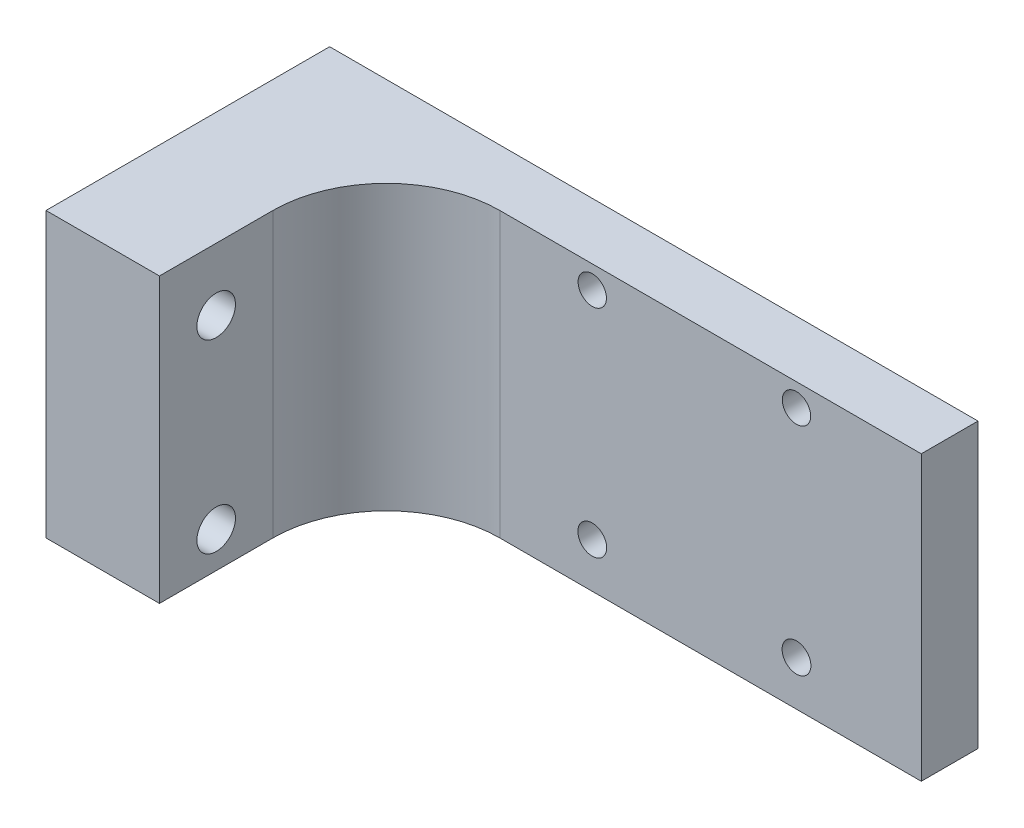
from build123d import *

# Parameters (mm, degrees)
SKETCH1_W           = 57.15
SKETCH1_H           = 25
BOSS_EXTRUDE1_DEPTH = 5
SKETCH2_R           = 1.25
SKETCH2_R_2         = 1.27
CUT_EXTRUDE2_DEPTH  = 6
SKETCH5_W           = 10
SKETCH5_H           = 25
BOSS_EXTRUDE3_DEPTH = 20
FILLET1_R           = 10
SKETCH6_R           = 1.7
CUT_EXTRUDE3_DEPTH  = 11


with BuildPart() as part:
    # Sketch1 → Boss-Extrude1 (new body)
    with BuildSketch(Plane.XY):
        with Locations((28.575, -12.5)):
            Rectangle(SKETCH1_W, SKETCH1_H)
    extrude(amount=BOSS_EXTRUDE1_DEPTH)

    # Sketch2 → Cut-Extrude2 (cut, through all)
    with BuildSketch(Plane.XY.offset(5)):
        with Locations((28.15, -2)):
            Circle(SKETCH2_R)
        with Locations((46.15, -2)):
            Circle(SKETCH2_R)
        with Locations((28.15, -21.05)):
            Circle(SKETCH2_R_2)
        with Locations((46.15, -21.05)):
            Circle(SKETCH2_R_2)
    extrude(amount=-CUT_EXTRUDE2_DEPTH, mode=Mode.SUBTRACT)

    # Sketch5 → Boss-Extrude3 (add)
    with BuildSketch(Plane.XY.offset(5)):
        with Locations((5, -12.5)):
            Rectangle(SKETCH5_W, SKETCH5_H)
    extrude(amount=BOSS_EXTRUDE3_DEPTH)

    # Fillet1
    fillet1_edges = [part.edges().sort_by_distance(p)[0] for p in [
        (10, -12.5, 5),
    ]]
    fillet(fillet1_edges, radius=FILLET1_R)

    # Sketch6 → Cut-Extrude3 (cut, through all)
    with BuildSketch(Plane(origin=(10, 0, 0), x_dir=(0, 0, -1), z_dir=(1, 0, 0))):
        with Locations((-20, -21.834919238)):
            Circle(SKETCH6_R)
        with Locations((-20, -5.503108416)):
            Circle(SKETCH6_R)
    extrude(amount=-CUT_EXTRUDE3_DEPTH, mode=Mode.SUBTRACT)


solid = part.part
